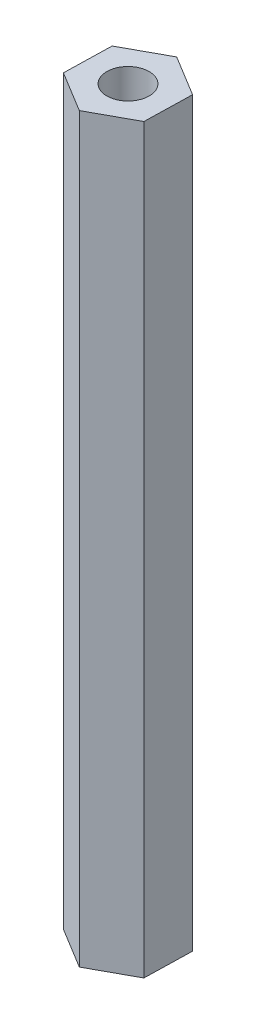
from build123d import *

# Parameters (mm, degrees)
BOSS_EXTRUDE1_DEPTH = 57.15
SKETCH2_R           = 3.2639
CUT_EXTRUDE1_DEPTH  = 12.7


with BuildPart() as part:
    # Sketch1 → Boss-Extrude1 (new body, symmetric)
    with BuildSketch(Plane(origin=(0, 0, 0), x_dir=(1, 0, 0), z_dir=(0, 1, 0))):
        Polygon((6.434399754, 3.515939866), (0.172306635, 7.330323578), (-6.262093119, 3.814383712), (-6.434399754, -3.515939866), (-0.172306635, -7.330323578), (6.262093119, -3.814383712), align=None)
    extrude(amount=BOSS_EXTRUDE1_DEPTH, both=True)

    # Sketch2 → Cut-Extrude1 (cut)
    with BuildSketch(Plane(origin=(0, 57.15, 0), x_dir=(1, 0, 0), z_dir=(0, 1, 0))):
        Circle(SKETCH2_R)
    cut_extrude1 = extrude(amount=-CUT_EXTRUDE1_DEPTH, mode=Mode.SUBTRACT)

    # Mirror1: Cut-Extrude1 across plane
    add(cut_extrude1.mirror(Plane.ZX), mode=Mode.SUBTRACT)


solid = part.part
